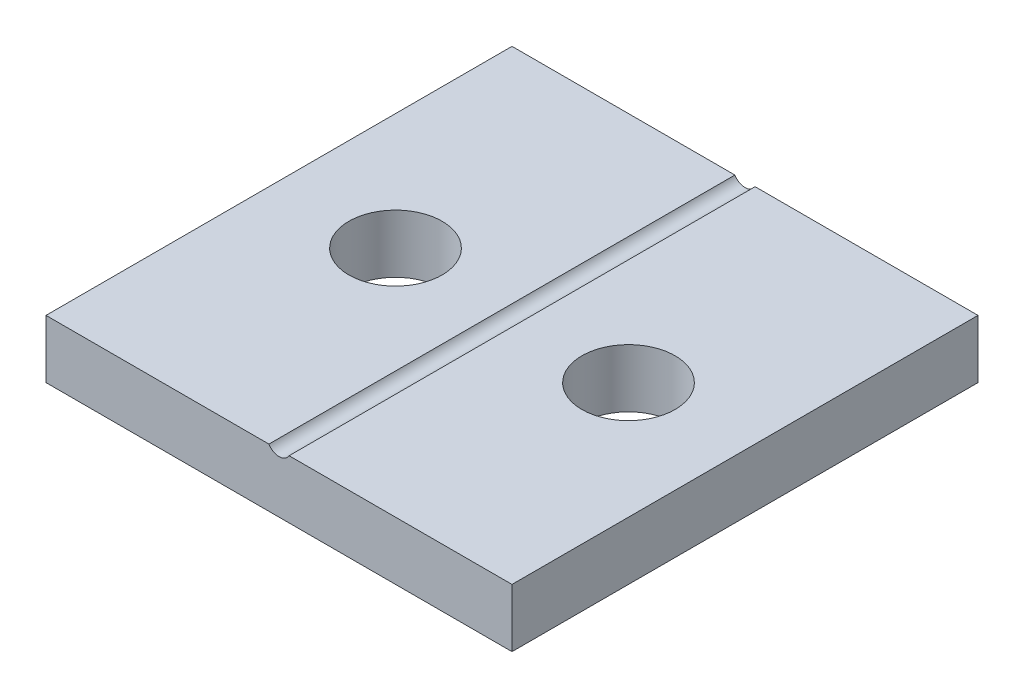
from build123d import *

# Parameters (mm, degrees)
SKETCH1_W           = 20
SKETCH1_H           = 20
BOSS_EXTRUDE1_DEPTH = 2.5
SKETCH2_R           = 0.5
CUT_EXTRUDE1_DEPTH  = 21
SKETCH3_R           = 2
CUT_EXTRUDE2_DEPTH  = 3.5


with BuildPart() as part:
    # Sketch1 → Boss-Extrude1 (new body)
    with BuildSketch(Plane(origin=(0, 0, 0), x_dir=(1, 0, 0), z_dir=(0, 1, 0))):
        with Locations((-50.754716981, 42.075471698)):
            Rectangle(SKETCH1_W, SKETCH1_H)
    extrude(amount=BOSS_EXTRUDE1_DEPTH)

    # Sketch2 → Cut-Extrude1 (cut, through all)
    with BuildSketch(Plane.XY.offset(-32.075471698)):
        with Locations((-50.754716981, 2.75)):
            Circle(SKETCH2_R)
    extrude(amount=-CUT_EXTRUDE1_DEPTH, mode=Mode.SUBTRACT)

    # Sketch3 → Cut-Extrude2 (cut, through all)
    with BuildSketch(Plane(origin=(0, 2.5, 0), x_dir=(1, 0, 0), z_dir=(0, 1, 0))):
        with Locations((-55.754716981, 42.075471698)):
            Circle(SKETCH3_R)
        with Locations((-45.754716981, 42.075471698)):
            Circle(SKETCH3_R)
    extrude(amount=-CUT_EXTRUDE2_DEPTH, mode=Mode.SUBTRACT)


solid = part.part
